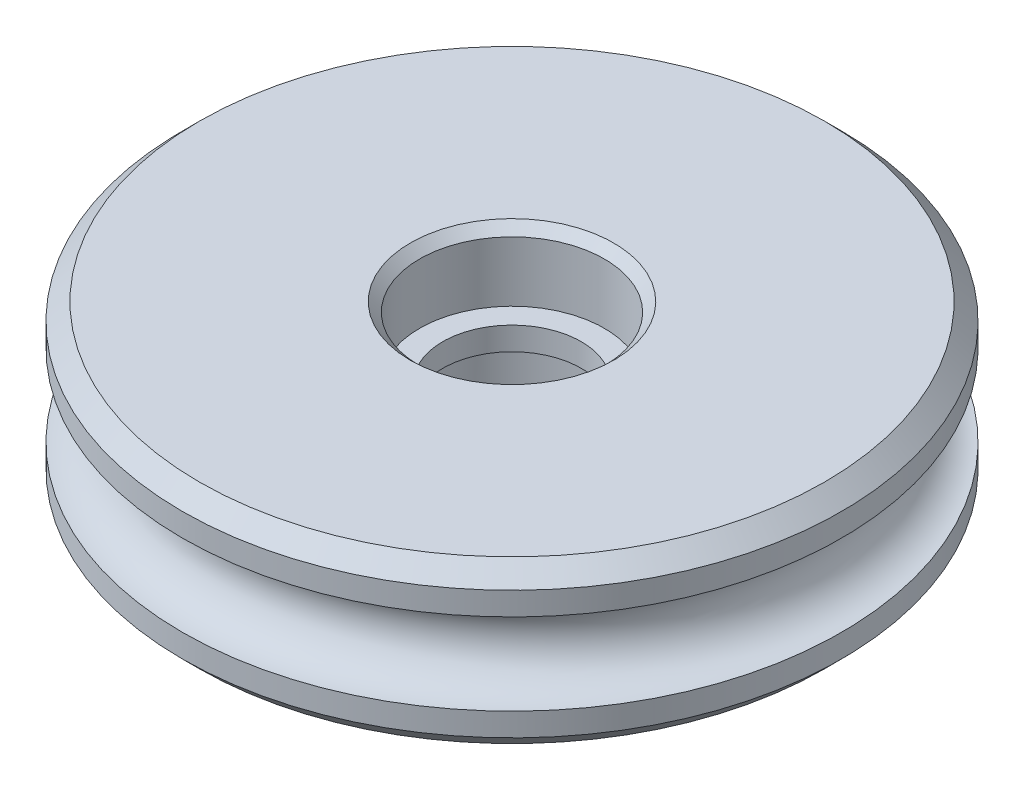
from build123d import *

# Parameters (mm, degrees)
CHAMFER1_SIZE = 0.4


with BuildPart() as part:
    # Sketch1 → Revolve1 (revolve)
    with BuildSketch(Plane(origin=(0, 0, 0), x_dir=(0, 0, -1), z_dir=(1, 0, 0))):
        with BuildLine():
            Line((-4, 3.5), (-13.5274, 3.5))
            Line((-13.5274, 3.5), (-14.2621, 2.7653))
            Line((-14.2621, 2.7653), (-14.2621, 1.7653))
            ThreePointArc((-14.2621, 1.7653), (-13.013844399, 1.248255601), (-12.4968, 0))
            Line((-12.4968, 0), (-3, 0))
            Line((-3, 0), (-3, 0.5))
            Line((-3, 0.5), (-4, 0.5))
            Line((-4, 0.5), (-4, 3.5))
        make_face()
    revolve1 = revolve(axis=Axis((0, 19.017402143, 0), (0, -1, 0)))

    # Mirror1: Revolve1 across plane
    add(revolve1.mirror(Plane.ZX))

    # Chamfer1
    chamfer1_edges = [part.edges().sort_by_distance(p)[0] for p in [
        (0, 3.5, -4),
        (0, -3.5, -4),
    ]]
    chamfer(chamfer1_edges, length=CHAMFER1_SIZE)


solid = part.part
